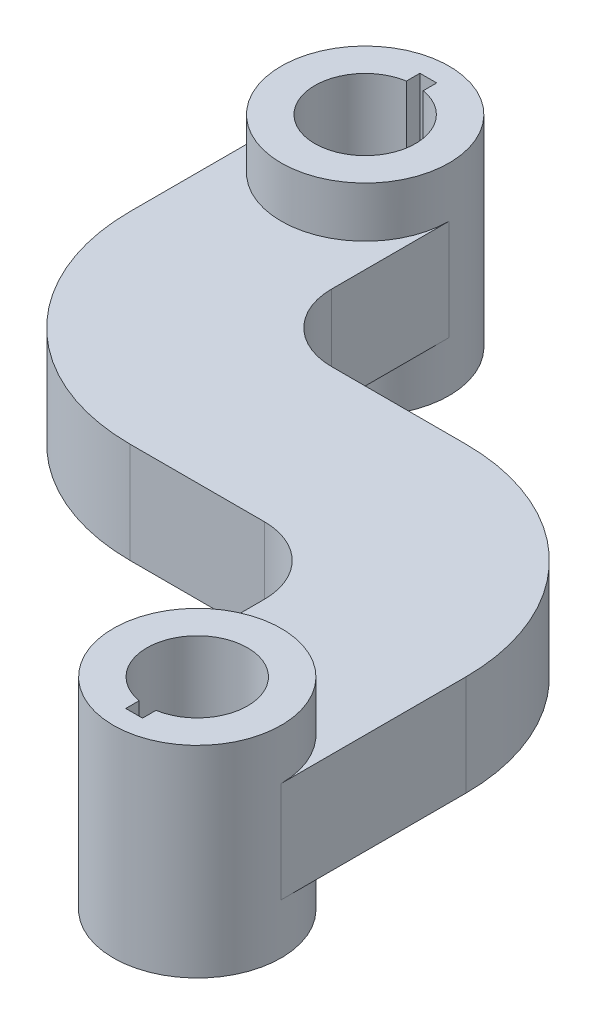
from build123d import *
from build123d.topology import SkipClean

# Parameters (mm, degrees)
BOSS_EXTRUDE1_DEPTH      = 19.05
BOSS_EXTRUDE2_DEPTH      = 19.05
BOSS_EXTRUDE2_DEPTH_BACK = 57.15
SKETCH2_R                = 31.75
CUT_EXTRUDE1_DEPTH       = 197.952392725


with BuildPart() as part:
    # Sketch1 → Boss-Extrude1 (new, symmetric)
    with BuildSketch(Plane(origin=(0, 0, 0), x_dir=(1, 0, 0), z_dir=(0, 1, 0))):
        with BuildLine():
            Line((0, -31.75), (-31.75, -31.75))
            ThreePointArc((-31.75, -31.75), (-85.631536726, -9.431536726), (-107.95, 44.45))
            Line((-107.95, 44.45), (-107.95, 101.6))
            ThreePointArc((-107.95, 101.6), (-76.2, 133.35), (-44.45, 101.6))
            Line((-44.45, 101.6), (-44.45, 57.15))
            ThreePointArc((-44.45, 57.15), (-37.010512242, 39.189487758), (-19.05, 31.75))
            Line((-19.05, 31.75), (0, 31.75))
            Line((0, 31.75), (31.75, 31.75))
            ThreePointArc((31.75, 31.75), (85.631536726, 9.431536726), (107.95, -44.45))
            Line((107.95, -44.45), (107.95, -114.3))
            ThreePointArc((107.95, -114.3), (76.2, -146.05), (44.45, -114.3))
            Line((44.45, -114.3), (44.45, -57.15))
            ThreePointArc((44.45, -57.15), (37.010512242, -39.189487758), (19.05, -31.75))
            Line((19.05, -31.75), (0, -31.75))
        make_face()
    extrude(amount=BOSS_EXTRUDE1_DEPTH, both=True)

    # Sketch2 → Boss-Extrude2 (add, two sides: drawn at the far end of the back side and taken through both)
    with SkipClean():  # the faces are left unmerged after this step: merging them gives an invalid solid
        with BuildSketch(Plane(origin=(0, 19.05, 0), x_dir=(1, 0, 0), z_dir=(0, 1, 0)).offset(-BOSS_EXTRUDE2_DEPTH_BACK)):
            with Locations((-76.2, 101.6)):
                Circle(SKETCH2_R)
            with Locations((76.2, -114.3)):
                Circle(SKETCH2_R)
        extrude(amount=BOSS_EXTRUDE2_DEPTH + BOSS_EXTRUDE2_DEPTH_BACK)

    # Sketch3 → Cut-Extrude1 (cut, through all)
    with SkipClean():  # the faces are left unmerged after this step: merging them gives an invalid solid
        with BuildSketch(Plane(origin=(0, 38.1, 0), x_dir=(1, 0, 0), z_dir=(0, 1, 0))):
            with BuildLine():
                Line((-79.375, 125.476), (-73.025, 125.476))
                Line((-73.025, 125.476), (-73.025, 120.383553311))
                ThreePointArc((-73.025, 120.383553311), (-76.2, 82.55), (-79.375, 120.383553311))
                Line((-79.375, 120.383553311), (-79.375, 125.476))
            make_face()
            with BuildLine():
                Line((73.025, -138.176), (79.375, -138.176))
                Line((79.375, -138.176), (79.375, -133.083553311))
                ThreePointArc((79.375, -133.083553311), (76.2, -95.25), (73.025, -133.083553311))
                Line((73.025, -133.083553311), (73.025, -138.176))
            make_face()
        extrude(amount=-CUT_EXTRUDE1_DEPTH, mode=Mode.SUBTRACT)


solid = part.part
